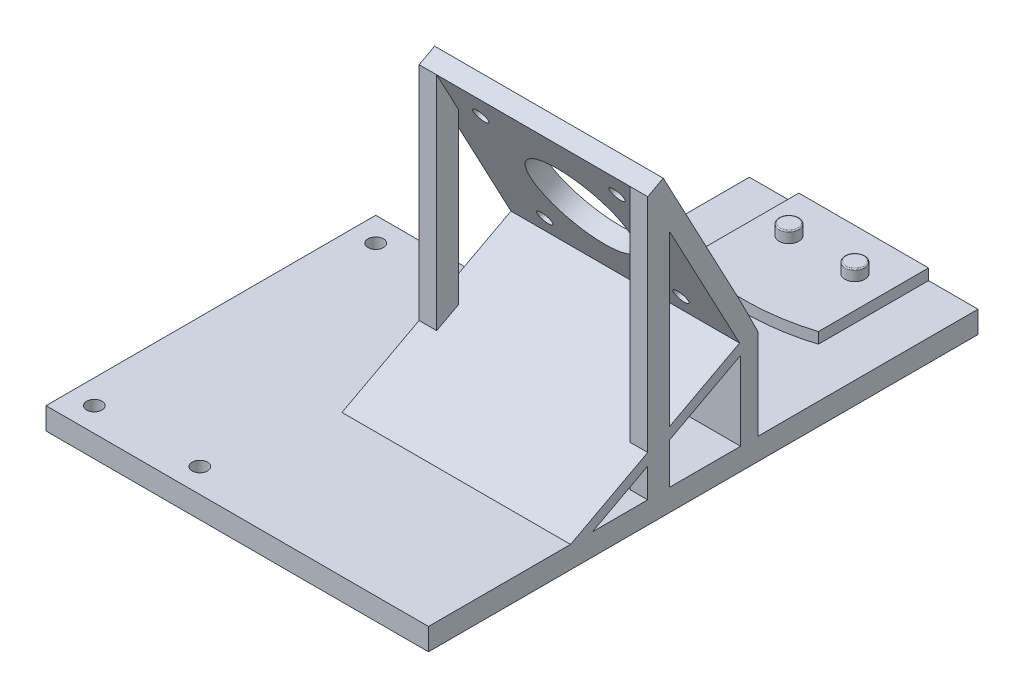
from build123d import *

# Parameters (mm, degrees)
SKETCH1_W                                           = 52
SKETCH1_H                                           = 100
BOSS_EXTRUDE1_DEPTH                                 = 5
BOSS_EXTRUDE3_DEPTH                                 = 2.5
SKETCH7_R                                           = 2.25
BOSS_EXTRUDE4_DEPTH                                 = 2.5
FILLET2_R                                           = 0.25
SKETCH9_W                                           = 52
SKETCH9_H                                           = 4
BOSS_EXTRUDE5_DEPTH                                 = 50
BOSS_EXTRUDE7_DEPTH                                 = 52
CUT_EXTRUDE3_DEPTH                                  = 52
CUT_EXTRUDE4_DEPTH                                  = 2.5
BOSS_EXTRUDE8_DEPTH                                 = 52
BOSS_EXTRUDE9_DEPTH                                 = 4
LPATTERN1_COUNT                                     = 2
LPATTERN1_PITCH                                     = 48
SKETCH18_R                                          = 11.5
CUT_EXTRUDE5_DEPTH                                  = 4
CSK_FOR_M3_COUNTERSUNK_FLAT_HEAD_SCREW1_D           = 3.4
CSK_FOR_M3_COUNTERSUNK_FLAT_HEAD_SCREW1_DEPTH       = 5
CSK_FOR_M3_COUNTERSUNK_FLAT_HEAD_SCREW1_CSINK_D     = 6.3
CSK_FOR_M3_COUNTERSUNK_FLAT_HEAD_SCREW1_CSINK_ANGLE = 90
CSK_FOR_M3_COUNTERSUNK_FLAT_HEAD_SCREW1_TIP         = 1.021463052
BOSS_EXTRUDE10_DEPTH                                = 5
SKETCH23_R                                          = 1.75
CUT_EXTRUDE6_DEPTH                                  = 5
SKETCH24_W                                          = 6.6
SKETCH24_H                                          = 5.6
CUT_EXTRUDE7_DEPTH                                  = 2.5


with BuildPart() as part:
    # Sketch1 → Boss-Extrude1 (new body)
    with BuildSketch(Plane(origin=(0, 0, 0), x_dir=(1, 0, 0), z_dir=(0, 1, 0))):
        Rectangle(SKETCH1_W, SKETCH1_H)
    extrude(amount=BOSS_EXTRUDE1_DEPTH)

    # Sketch2 → Boss-Extrude3 (add)
    with BuildSketch(Plane(origin=(0, 5, 0), x_dir=(1, 0, 0), z_dir=(0, 1, 0))):
        with BuildLine():
            Line((-26, 50), (26, 50))
            Line((26, 50), (26, 30))
            ThreePointArc((26, 30), (0, 22.708313008), (-26, 30))
            Line((-26, 30), (-26, 50))
        make_face()
    extrude(amount=BOSS_EXTRUDE3_DEPTH)

    # Sketch7 → Boss-Extrude4 (add)
    with BuildSketch(Plane(origin=(0, 7.5, 0), x_dir=(1, 0, 0), z_dir=(0, 1, 0))):
        with Locations((-7.5, 40.5)):
            Circle(SKETCH7_R)
        with Locations((7.5, 40.5)):
            Circle(SKETCH7_R)
    extrude(amount=BOSS_EXTRUDE4_DEPTH)

    # Fillet2
    fillet2_edges = [part.edges().sort_by_distance(p)[0] for p in [
        (-9.75, 10, -40.5),
        (5.25, 10, -40.5),
    ]]
    fillet(fillet2_edges, radius=FILLET2_R)

    # Sketch9 → Boss-Extrude5 (add)
    with BuildSketch(Plane(origin=(0, 5, 0), x_dir=(1, 0, 0), z_dir=(0, 1, 0))):
        with Locations((0, -2)):
            Rectangle(SKETCH9_W, SKETCH9_H)
    extrude(amount=BOSS_EXTRUDE5_DEPTH)

    # Sketch10 → Boss-Extrude7 (add)
    with BuildSketch(Plane.ZY.offset(26)):
        Polygon((4, 25), (25.126220325, 64.732641679), (21.594429954, 66.61052793), (4, 33.520217873), align=None)
    extrude(amount=-BOSS_EXTRUDE7_DEPTH)

    # Sketch11 → Cut-Extrude3 (cut)
    with BuildSketch(Plane.ZY.offset(26)):
        Polygon((4, 33.520217873), (0, 25.498656006), (0, 55), (4, 55), align=None)
    extrude(amount=-CUT_EXTRUDE3_DEPTH, mode=Mode.SUBTRACT)

    # Sketch13 → Cut-Extrude4 (cut)
    with BuildSketch(Plane(origin=(0, 7.5, 0), x_dir=(1, 0, 0), z_dir=(0, 1, 0))):
        with BuildLine():
            Line((-14.75, 24.933450371), (-14.75, 50))
            Line((-14.75, 50), (-26, 50))
            Line((-26, 50), (-26, 30))
            ThreePointArc((-26, 30), (-20.531880242, 27.118381074), (-14.75, 24.933450371))
        make_face()
        with BuildLine():
            Line((26, 50), (14.75, 50))
            Line((14.75, 50), (14.75, 24.933450371))
            ThreePointArc((14.75, 24.933450371), (20.531880242, 27.118381074), (26, 30))
            Line((26, 30), (26, 50))
        make_face()
    extrude(amount=-CUT_EXTRUDE4_DEPTH, mode=Mode.SUBTRACT)

    # Sketch16 → Boss-Extrude8 (add)
    with BuildSketch(Plane.ZY.offset(26)):
        Polygon((4.234735781, 25.441473796), (42.679556541, 5), (37.679556541, 5), (4, 22.907737867), (4, 25), align=None)
    extrude(amount=-BOSS_EXTRUDE8_DEPTH)

    # Sketch17 → Boss-Extrude9 (add)
    with BuildSketch(Plane.ZY.offset(26)):
        Polygon((25.126220325, 64.732641679), (25.126220325, 5), (20.126220325, 5), (20.126220325, 55.329009352), align=None)
    boss_extrude9 = extrude(amount=-BOSS_EXTRUDE9_DEPTH)

    # LPattern1: Boss-Extrude9 ×2
    with Locations(*[(i * LPATTERN1_PITCH, 0, 0) for i in range(1, LPATTERN1_COUNT)]):
        add(boss_extrude9)

    # Sketch18 → Cut-Extrude5 (cut)
    with BuildSketch(Plane(origin=(0, 5.729899813, -10.776374221), x_dir=(-1, 0, 0), z_dir=(0, 0.469471563, -0.882947593))):
        with Locations((0, 45.951576073)):
            Circle(SKETCH18_R)
    extrude(amount=-CUT_EXTRUDE5_DEPTH, mode=Mode.SUBTRACT)

    # CSK for M3 Countersunk Flat Head Screw1
    with Locations(Plane(origin=(0, 5.729899813, -10.776374221), x_dir=(-1, 0, 0), z_dir=(0, 0.469471563, -0.882947593))):
        with Locations((-15.5, 61.451576073), (15.5, 61.451576073), (15.5, 30.451576073), (-15.5, 30.451576073)):
            CounterSinkHole(CSK_FOR_M3_COUNTERSUNK_FLAT_HEAD_SCREW1_D / 2, CSK_FOR_M3_COUNTERSUNK_FLAT_HEAD_SCREW1_CSINK_D / 2, depth=CSK_FOR_M3_COUNTERSUNK_FLAT_HEAD_SCREW1_DEPTH, counter_sink_angle=CSK_FOR_M3_COUNTERSUNK_FLAT_HEAD_SCREW1_CSINK_ANGLE)
            with Locations((0, 0, -(CSK_FOR_M3_COUNTERSUNK_FLAT_HEAD_SCREW1_DEPTH + CSK_FOR_M3_COUNTERSUNK_FLAT_HEAD_SCREW1_TIP / 2))):  # 118° drill point
                Cone(0, CSK_FOR_M3_COUNTERSUNK_FLAT_HEAD_SCREW1_D / 2, CSK_FOR_M3_COUNTERSUNK_FLAT_HEAD_SCREW1_TIP, mode=Mode.SUBTRACT)

    # Sketch22 → Boss-Extrude10 (add)
    with BuildSketch(Plane.XZ):
        Polygon((26, 75), (-61, 75), (-61, 0), (-26, 0), (-26, 50), (26, 50), align=None)
    extrude(amount=-BOSS_EXTRUDE10_DEPTH)

    # Sketch23 → Cut-Extrude6 (cut)
    with BuildSketch(Plane(origin=(0, 5, 0), x_dir=(1, 0, 0), z_dir=(0, 1, 0))):
        with Locations((-31.5, -5.5)):
            Circle(SKETCH23_R)
        with Locations((-55.5, -5.5)):
            Circle(SKETCH23_R)
        with Locations((-55.5, -69.5)):
            Circle(SKETCH23_R)
        with Locations((-31.5, -69.5)):
            Circle(SKETCH23_R)
    extrude(amount=-CUT_EXTRUDE6_DEPTH, mode=Mode.SUBTRACT)

    # Sketch24 → Cut-Extrude7 (cut)
    with BuildSketch(Plane.XZ):
        with Locations((-31.5, 69.5)):
            Rectangle(SKETCH24_W, SKETCH24_H)
        with Locations((-55.5, 69.5)):
            Rectangle(SKETCH24_W, SKETCH24_H)
        with Locations((-31.5, 5.5)):
            Rectangle(SKETCH24_W, SKETCH24_H)
        with Locations((-55.5, 5.5)):
            Rectangle(SKETCH24_W, SKETCH24_H)
    extrude(amount=-CUT_EXTRUDE7_DEPTH, mode=Mode.SUBTRACT)


solid = part.part
